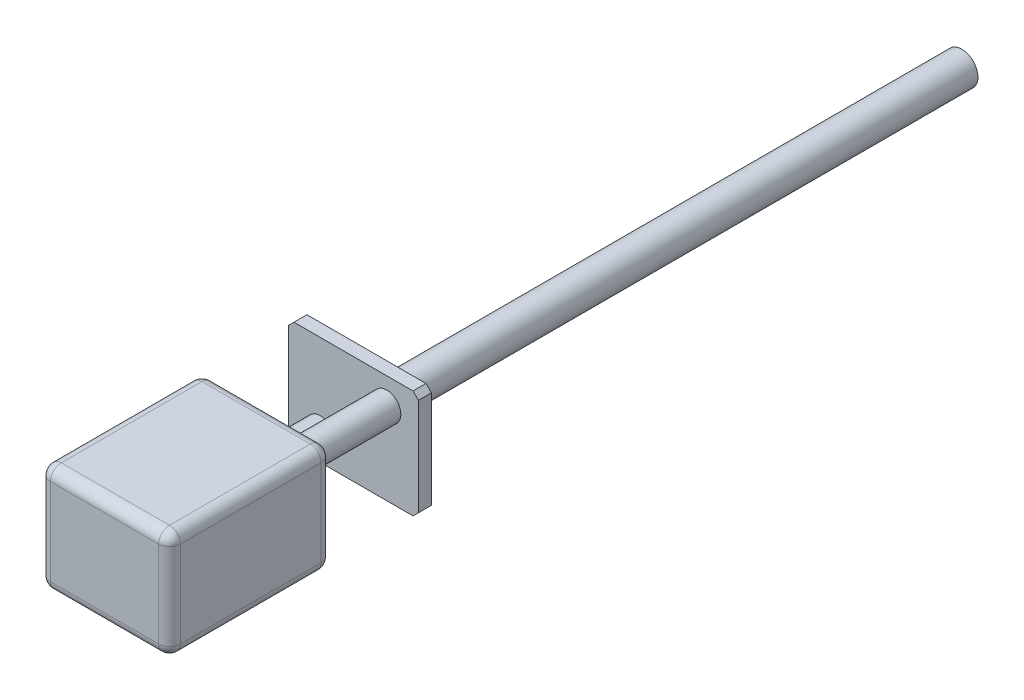
from build123d import *

# Parameters (mm, degrees)
SKETCH_1_W          = 12
SKETCH_1_H          = 10
EXTRUDE_1_DEPTH     = 15
FILLET_1_R          = 1
SKETCH_2_R          = 1.3
SKETCH_2_R_2        = 0.8
EXTRUDE_2_DEPTH     = 8
EXTRUDE_3_DEPTH     = 1.2
SKETCH_6_R          = 0.8
CUT_EXTRUDE_1_DEPTH = 1.2
SKETCH_7_R          = 1.5
EXTRUDE_4_DEPTH     = 55


with BuildPart() as part:
    # 草图1 → 凸台-拉伸1 (new body)
    with BuildSketch(Plane.XY):
        with Locations((6, 5)):
            Rectangle(SKETCH_1_W, SKETCH_1_H)
    extrude(amount=EXTRUDE_1_DEPTH)

    # 圆角1
    fillet_1_edges = [part.edges().sort_by_distance(p)[0] for p in [
        (12, 5, 15),
        (6, 10, 15),
        (0, 5, 15),
        (6, 10, 0),
        (12, 5, 0),
        (6, 0, 0),
        (0, 5, 0),
        (6, 0, 15),
        (0, 10, 7.5),
        (12, 10, 7.5),
        (12, 0, 7.5),
        (0, 0, 7.5),
    ]]
    fillet(fillet_1_edges, radius=FILLET_1_R)

    # 草图2 → 凸台-拉伸2 (add)
    with BuildSketch(Plane(origin=(0, 0, 0), x_dir=(-1, 0, 0), z_dir=(0, 0, -1))):
        with Locations((-2.927114882, 2.439262401)):
            Circle(SKETCH_2_R)
        with Locations((-2.927114882, 2.439262401)):
            Circle(SKETCH_2_R_2, mode=Mode.SUBTRACT)
        with Locations((-9.072885118, 7.560737599)):
            Circle(SKETCH_2_R)
        with Locations((-9.072885118, 7.560737599)):
            Circle(SKETCH_2_R_2, mode=Mode.SUBTRACT)
    extrude(amount=EXTRUDE_2_DEPTH)

    # 草图3 → 凸台-拉伸3 (add)
    with BuildSketch(Plane(origin=(0, 0, -8), x_dir=(-1, 0, 0), z_dir=(0, 0, -1))):
        Polygon((0, 0.5), (-0.5, 0), (-11.5, 0), (-12, 0.5), (-12, 9.5), (-11.5, 10), (-0.5, 10), (0, 9.5), align=None)
    extrude(amount=EXTRUDE_3_DEPTH)

    # 草图6 → 切除-拉伸1 (cut)
    with BuildSketch(Plane(origin=(0, 0, -9.2), x_dir=(-1, 0, 0), z_dir=(0, 0, -1))):
        with Locations((-2.927114882, 2.439262401)):
            Circle(SKETCH_6_R)
        with Locations((-9.072885118, 7.560737599)):
            Circle(SKETCH_6_R)
    extrude(amount=-CUT_EXTRUDE_1_DEPTH, mode=Mode.SUBTRACT)

    # 草图7 → 凸台-拉伸4 (add)
    with BuildSketch(Plane.XY.offset(-9.2)):
        with Locations((6, 5)):
            Circle(SKETCH_7_R)
    extrude(amount=-EXTRUDE_4_DEPTH)


solid = part.part
